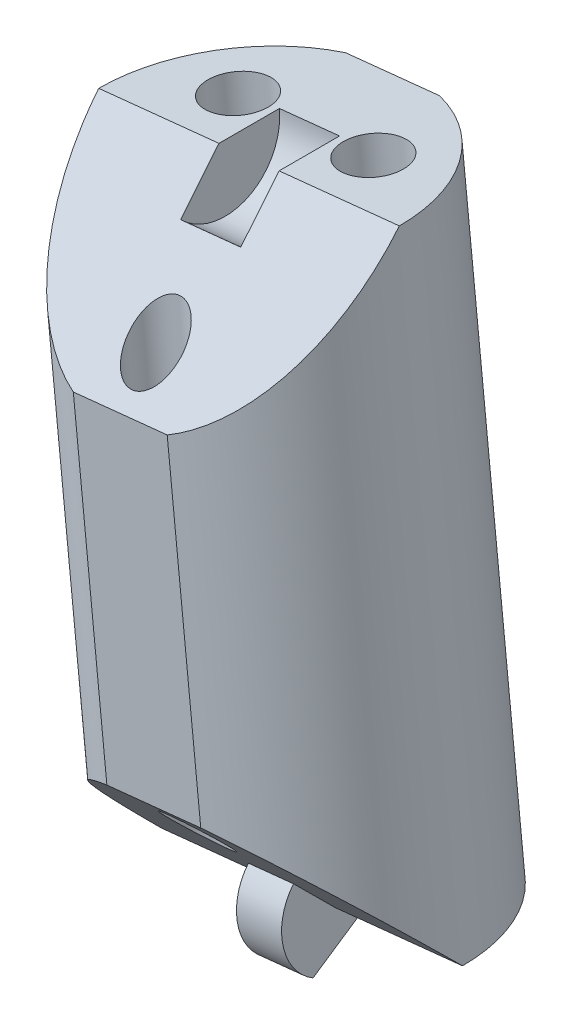
from build123d import *

# Parameters (mm, degrees)
SKETCH3_R               = 8
BOSS_EXTRUDE1_DEPTH     = 32.422105263
CUT_EXTRUDE1_DEPTH      = 12.326517504
CUT_EXTRUDE1_DEPTH_BACK = 12.326517504
BOSS_EXTRUDE2_DEPTH     = 1.2
CUT_EXTRUDE2_DEPTH      = 1.6
SKETCH8_R               = 1.4
SKETCH8_R_2             = 1.6
CUT_EXTRUDE3_DEPTH      = 2.64160469
CUT_EXTRUDE3_DEPTH_BACK = 36.765098388
CUT_EXTRUDE4_DEPTH      = 36.765098388


with BuildPart() as part:
    # Sketch3 → Boss-Extrude1 (new body)
    with BuildSketch(Plane(origin=(-20.344467381, 196.178792599, 0), x_dir=(-0.994665758, -0.103150523, 0), z_dir=(0.103150523, -0.994665758, 0))):
        with Locations((-10.431405186, 0)):
            Circle(SKETCH3_R)
    extrude(amount=BOSS_EXTRUDE1_DEPTH)

    # Sketch4 → Cut-Extrude1 (cut, two sides)
    with BuildSketch(Plane(origin=(10.375761543, 1.076004901, 0), x_dir=(0.103150523, -0.994665758, 0), z_dir=(-0.994665758, -0.103150523, 0))) as cut_extrude1_sk:
        Polygon((-197.230869842, 0), (-189.230869842, 8), (-197.230869842, 8), align=None)
        Polygon((-172.808764579, 8), (-164.808764579, 8), (-164.808764579, 0), align=None)
    extrude(amount=CUT_EXTRUDE1_DEPTH, mode=Mode.SUBTRACT)
    extrude(cut_extrude1_sk.sketch, amount=-CUT_EXTRUDE1_DEPTH_BACK, mode=Mode.SUBTRACT)

    # Sketch5 → Boss-Extrude2 (add, symmetric)
    with BuildSketch(Plane(origin=(10.375761543, 1.076004901, 0), x_dir=(0.103150523, -0.994665758, 0), z_dir=(-0.994665758, -0.103150523, 0))):
        with BuildLine():
            Line((-164.808764579, -2.8), (-162.383893448, 1.4))
            ThreePointArc((-162.383893448, 1.4), (-164.443291241, 2.776045612), (-166.788663566, 1.979898987))
            Line((-166.788663566, 1.979898987), (-164.808764579, 0))
            Line((-164.808764579, 0), (-164.808764579, -2.8))
        make_face()
    extrude(amount=BOSS_EXTRUDE2_DEPTH, both=True)

    # Sketch7 → Cut-Extrude2 (cut, symmetric)
    with BuildSketch(Plane(origin=(10.375761543, 1.076004901, 0), x_dir=(0.103150523, -0.994665758, 0), z_dir=(-0.994665758, -0.103150523, 0))):
        with BuildLine():
            Line((-194.968128142, 2.2627417), (-197.230869842, 0))
            Line((-197.230869842, 0), (-197.230869842, -3.2))
            ThreePointArc((-197.230869842, -3.2), (-194.274455338, -1.224586984), (-194.968128142, 2.2627417))
        make_face()
    extrude(amount=CUT_EXTRUDE2_DEPTH, both=True, mode=Mode.SUBTRACT)

    # Sketch8 → Cut-Extrude3 (cut, two sides)
    with BuildSketch(Plane(origin=(-20.344467381, 196.178792599, 0), x_dir=(0.994665758, 0.103150523, 0), z_dir=(-0.103150523, 0.994665758, 0))) as cut_extrude3_sk:
        with Locations((10.431405186, -5.5)):
            Circle(SKETCH8_R)
        with Locations((6.831405186, 3)):
            Circle(SKETCH8_R_2)
        with Locations((14.031405186, 3)):
            Circle(SKETCH8_R_2)
    extrude(amount=CUT_EXTRUDE3_DEPTH, mode=Mode.SUBTRACT)
    extrude(cut_extrude3_sk.sketch, amount=-CUT_EXTRUDE3_DEPTH_BACK, mode=Mode.SUBTRACT)

    # Sketch9 → Cut-Extrude4 (cut, through all)
    with BuildSketch(Plane(origin=(-20.344467381, 196.178792599, 0), x_dir=(0.994665758, 0.103150523, 0), z_dir=(-0.103150523, 0.994665758, 0))):
        with BuildLine():
            Line((7.933405986, 7.6), (12.929404385, 7.6))
            ThreePointArc((12.929404385, 7.6), (10.431405186, 8), (7.933405986, 7.6))
        make_face()
        with BuildLine():
            Line((7.933405986, -7.6), (12.929404385, -7.6))
            ThreePointArc((12.929404385, -7.6), (10.431405186, -8), (7.933405986, -7.6))
        make_face()
    extrude(amount=-CUT_EXTRUDE4_DEPTH, mode=Mode.SUBTRACT)


solid = part.part
